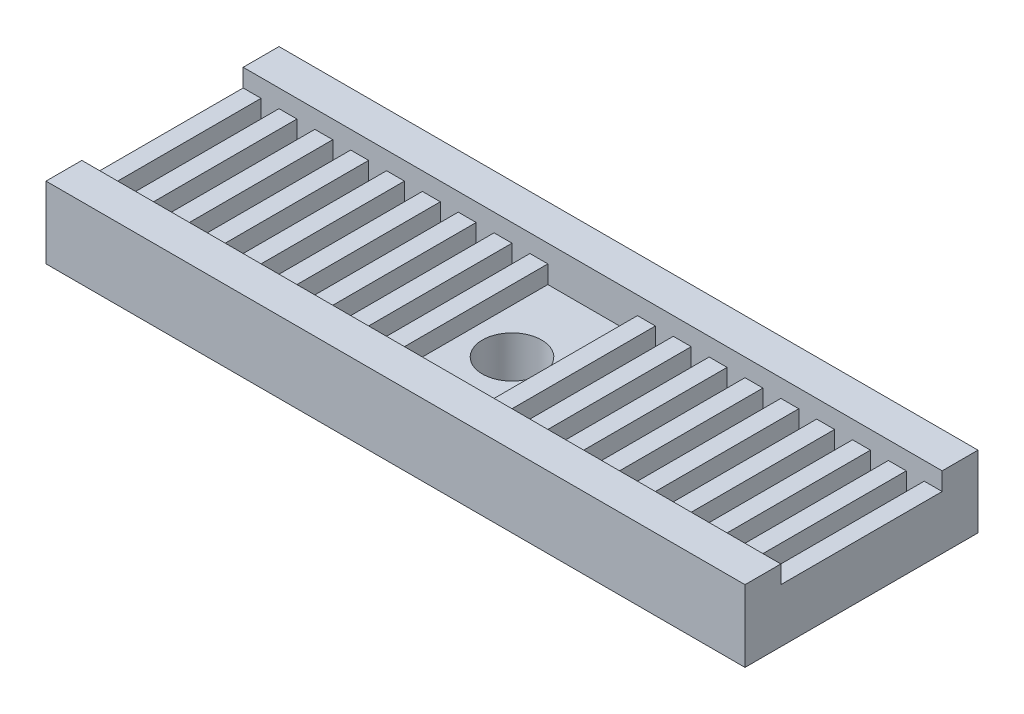
from build123d import *

# Parameters (mm, degrees)
SKETCH1_W           = 39
SKETCH1_H           = 13
BOSS_EXTRUDE1_DEPTH = 5
SKETCH5_W           = 39
SKETCH5_H           = 9
CUT_EXTRUDE1_DEPTH  = 2
SKETCH2_W           = 1
SKETCH2_H           = 9
BOSS_EXTRUDE2_DEPTH = 1
SKETCH6_R           = 1.65
CUT_EXTRUDE2_DEPTH  = 6
CHAMFER1_SIZE       = 1


with BuildPart() as part:
    # Sketch1 → Boss-Extrude1 (new body)
    with BuildSketch(Plane(origin=(0, 0, 0), x_dir=(1, 0, 0), z_dir=(0, 1, 0))):
        Rectangle(SKETCH1_W, SKETCH1_H)
    extrude(amount=BOSS_EXTRUDE1_DEPTH)

    # Sketch5 → Cut-Extrude1 (cut)
    with BuildSketch(Plane(origin=(0, 5, 0), x_dir=(1, 0, 0), z_dir=(0, 1, 0))):
        Rectangle(SKETCH5_W, SKETCH5_H)
    extrude(amount=-CUT_EXTRUDE1_DEPTH, mode=Mode.SUBTRACT)

    # Sketch2 → Boss-Extrude2 (add)
    with BuildSketch(Plane(origin=(0, 3, 0), x_dir=(1, 0, 0), z_dir=(0, 1, 0))):
        with Locations((7, 0)):
            Rectangle(SKETCH2_W, SKETCH2_H)
        with Locations((5, 0)):
            Rectangle(SKETCH2_W, SKETCH2_H)
        with Locations((9, 0)):
            Rectangle(SKETCH2_W, SKETCH2_H)
        with Locations((3, 0)):
            Rectangle(SKETCH2_W, SKETCH2_H)
        with Locations((11, 0)):
            Rectangle(SKETCH2_W, SKETCH2_H)
        with Locations((13, 0)):
            Rectangle(SKETCH2_W, SKETCH2_H)
        with Locations((15, 0)):
            Rectangle(SKETCH2_W, SKETCH2_H)
        with Locations((-3, 0)):
            Rectangle(SKETCH2_W, SKETCH2_H)
        with Locations((17, 0)):
            Rectangle(SKETCH2_W, SKETCH2_H)
        with Locations((-5, 0)):
            Rectangle(SKETCH2_W, SKETCH2_H)
        with Locations((19, 0)):
            Rectangle(SKETCH2_W, SKETCH2_H)
        with Locations((-7, 0)):
            Rectangle(SKETCH2_W, SKETCH2_H)
        with Locations((-9, 0)):
            Rectangle(SKETCH2_W, SKETCH2_H)
        with Locations((-11, 0)):
            Rectangle(SKETCH2_W, SKETCH2_H)
        with Locations((-13, 0)):
            Rectangle(SKETCH2_W, SKETCH2_H)
        with Locations((-15, 0)):
            Rectangle(SKETCH2_W, SKETCH2_H)
        with Locations((-17, 0)):
            Rectangle(SKETCH2_W, SKETCH2_H)
        with Locations((-19, 0)):
            Rectangle(SKETCH2_W, SKETCH2_H)
    extrude(amount=BOSS_EXTRUDE2_DEPTH)

    # Sketch6 → Cut-Extrude2 (cut, through all)
    with BuildSketch(Plane.XZ):
        Circle(SKETCH6_R)
    extrude(amount=-CUT_EXTRUDE2_DEPTH, mode=Mode.SUBTRACT)

    # Chamfer1
    chamfer1_edges = [part.edges().sort_by_distance(p)[0] for p in [
        (-19.5, 0, 0),
        (0, 0, -6.5),
        (19.5, 0, 0),
        (0, 0, 6.5),
    ]]
    chamfer(chamfer1_edges, length=CHAMFER1_SIZE)


solid = part.part
